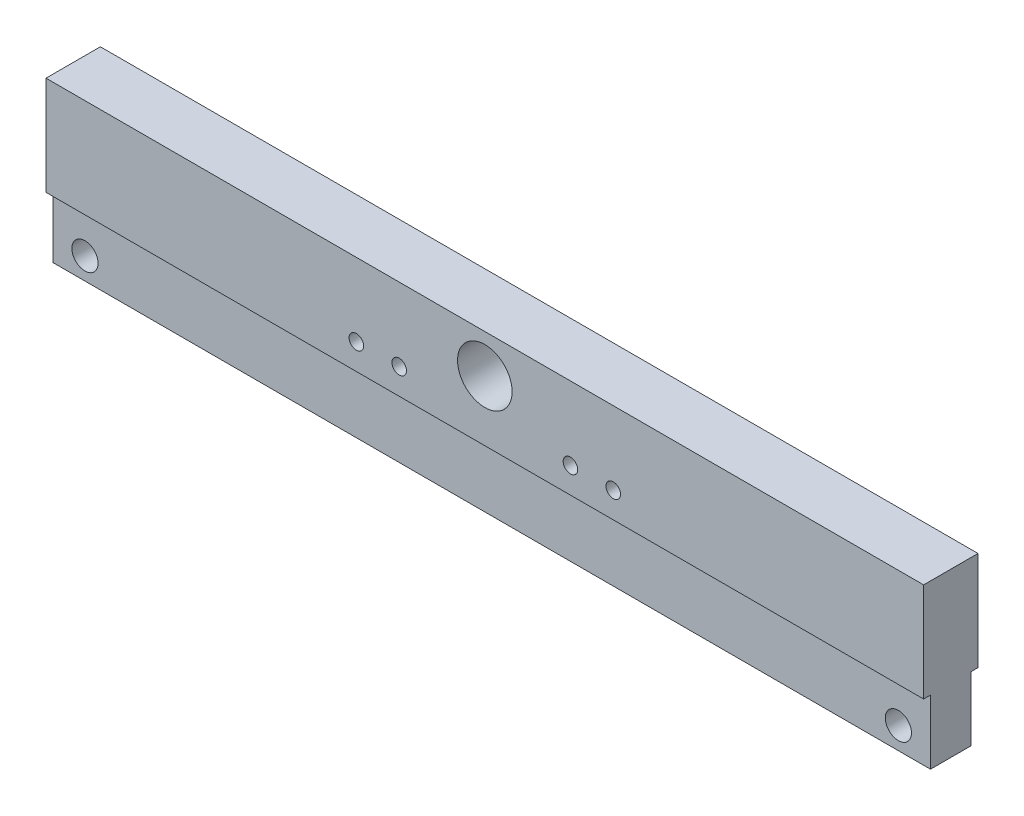
from build123d import *

# Parameters (mm, degrees)
SKETCH1_W           = 410
SKETCH1_H           = 76.2
SKETCH1_R           = 12.75
SKETCH1_R_2         = 6.125
BOSS_EXTRUDE1_DEPTH = 12.7
SKETCH2_R           = 6
CUT_EXTRUDE1_DEPTH  = 15
SKETCH4_OUTSIDE_W   = 495.558
SKETCH4_OUTSIDE_H   = 110.958
SKETCH4_OUTSIDE_W_2 = 410
SKETCH4_OUTSIDE_H_2 = 19
CUT_EXTRUDE2_DEPTH  = 30
M8_TAPPED_HOLE1_D   = 6.8


with BuildPart() as part:
    # Sketch1 → Boss-Extrude1 (new body, symmetric)
    with BuildSketch(Plane.XY):
        Rectangle(SKETCH1_W, SKETCH1_H)
        with Locations((0, 20.1)):
            Circle(SKETCH1_R, mode=Mode.SUBTRACT)
        with Locations((190, -27.9)):
            Circle(SKETCH1_R_2, mode=Mode.SUBTRACT)
        with Locations((-190, -27.9)):
            Circle(SKETCH1_R_2, mode=Mode.SUBTRACT)
    extrude(amount=BOSS_EXTRUDE1_DEPTH, both=True)

    # Sketch2 → Cut-Extrude1 (cut)
    with BuildSketch(Plane.XZ.offset(38.1)):
        Circle(SKETCH2_R)
        with Locations((-165, 0)):
            Circle(SKETCH2_R)
        with Locations((165, 0)):
            Circle(SKETCH2_R)
    extrude(amount=-CUT_EXTRUDE1_DEPTH, mode=Mode.SUBTRACT)

    # Sketch4 outside → Cut-Extrude2 (cut)
    with BuildSketch(Plane.XZ.offset(38.1)):
        Rectangle(SKETCH4_OUTSIDE_W, SKETCH4_OUTSIDE_H)
        Rectangle(SKETCH4_OUTSIDE_W_2, SKETCH4_OUTSIDE_H_2, mode=Mode.SUBTRACT)
    extrude(amount=-CUT_EXTRUDE2_DEPTH, mode=Mode.SUBTRACT)

    # M8 Tapped Hole1 (through all)
    with Locations(Plane.XY.offset(12.7)):
        with Locations((-60, 3.9), (-40, 3.9), (40, 3.9), (60, 3.9)):
            Hole(M8_TAPPED_HOLE1_D / 2)


solid = part.part
